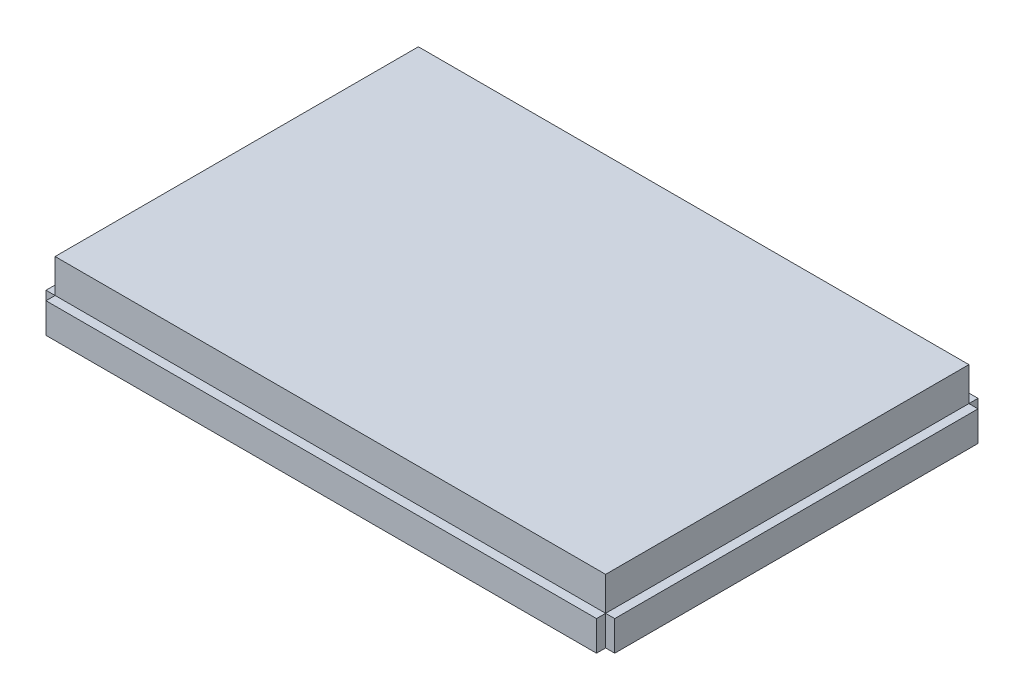
from build123d import *

# Parameters (mm, degrees)
SKETCH1_W           = 82.2198
SKETCH1_H           = 54.2544
BOSS_EXTRUDE1_DEPTH = 9.525
SKETCH2_W           = 82.2198
SKETCH2_H           = 4.4831
BOSS_EXTRUDE2_DEPTH = 1.3589
SKETCH3_W           = 54.2544
SKETCH3_H           = 4.4831
BOSS_EXTRUDE3_DEPTH = 1.3589


with BuildPart() as part:
    # Sketch1 → Boss-Extrude1 (new body)
    with BuildSketch(Plane(origin=(0, 0, 0), x_dir=(1, 0, 0), z_dir=(0, 1, 0))):
        Rectangle(SKETCH1_W, SKETCH1_H)
    extrude(amount=BOSS_EXTRUDE1_DEPTH)

    # Sketch2 → Boss-Extrude2 (add)
    with BuildSketch(Plane.XY.offset(27.1272)):
        with Locations((0, 2.24155)):
            Rectangle(SKETCH2_W, SKETCH2_H)
    boss_extrude2 = extrude(amount=BOSS_EXTRUDE2_DEPTH)

    # Mirror1: Boss-Extrude2 across plane
    add(boss_extrude2.mirror(Plane.XY))

    # Sketch3 → Boss-Extrude3 (add)
    with BuildSketch(Plane(origin=(41.1099, 0, 0), x_dir=(0, 0, -1), z_dir=(1, 0, 0))):
        with Locations((0, 2.24155)):
            Rectangle(SKETCH3_W, SKETCH3_H)
    boss_extrude3 = extrude(amount=BOSS_EXTRUDE3_DEPTH)

    # Mirror2: Boss-Extrude3 across plane
    add(boss_extrude3.mirror(Plane(origin=(0, 0, 0), x_dir=(0, 0, 1), z_dir=(1, 0, 0))))


solid = part.part
